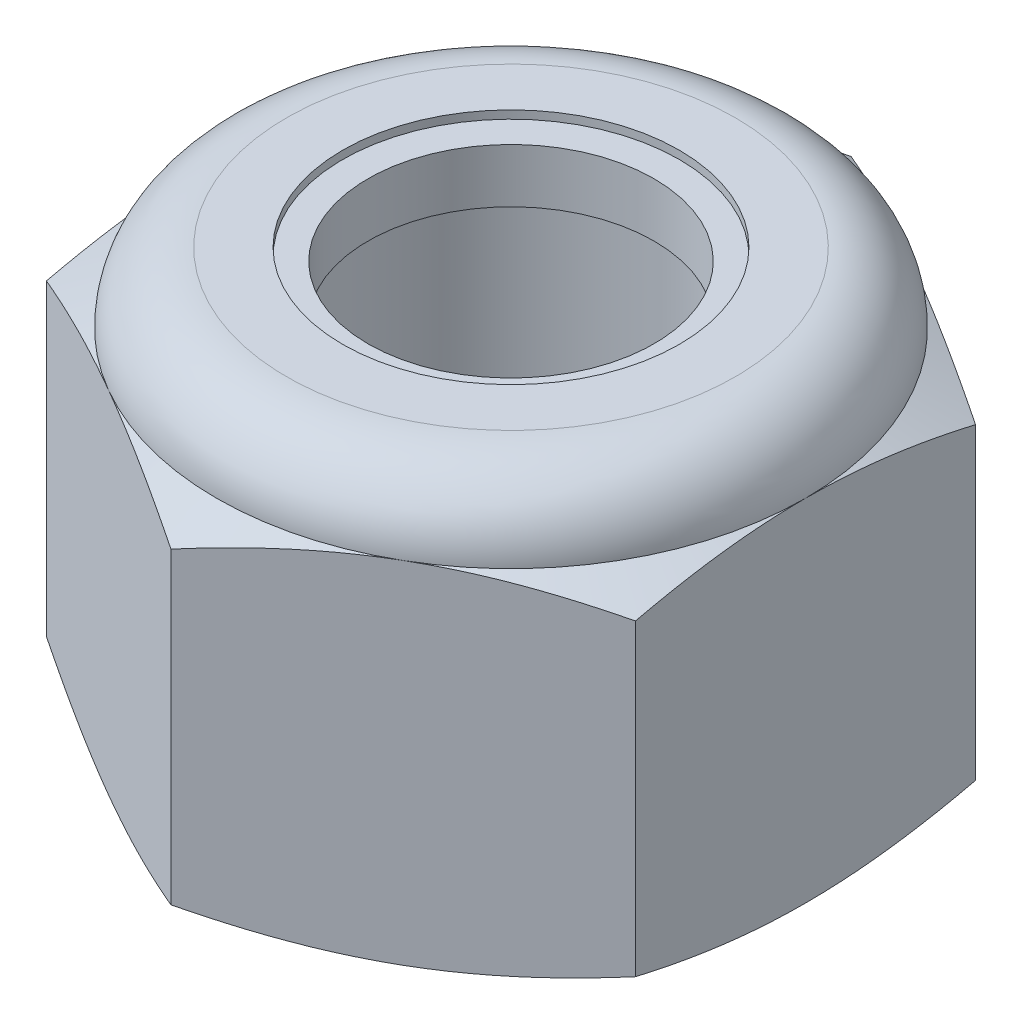
from build123d import *

# Parameters (mm, degrees)
SKETCH13_R     = 3.175
EXTRUDE1_DEPTH = 7.9375


with BuildPart() as part:
    # Sketch13 → Extrude1 (new body)
    with BuildSketch(Plane(origin=(0, 0, 0), x_dir=(1, 0, 0), z_dir=(0, 1, 0))):
        Polygon((0, 6.415804866), (-5.55625, 3.207902433), (-5.55625, -3.207902433), (0, -6.415804866), (5.55625, -3.207902433), (5.55625, 3.207902433), align=None)
        Circle(SKETCH13_R, mode=Mode.SUBTRACT)
    extrude(amount=EXTRUDE1_DEPTH)

    # Sketch5 → Cut-Revolve3 (revolve, cut)
    with BuildSketch(Plane(origin=(0, 0, 0), x_dir=(0, 0, -1), z_dir=(1, 0, 0))):
        with BuildLine():
            Line((0, 0), (5.55625, 0))
            Line((5.55625, 0), (6.415804866, 0.400817017))
            Line((6.415804866, 0.400817017), (6.415804866, 6.213766317))
            Line((6.415804866, 6.213766317), (5.55625, 6.614583333))
            ThreePointArc((5.55625, 6.614583333), (5.168776679, 7.550026679), (4.233333333, 7.9375))
            Line((4.233333333, 7.9375), (4.233333333, 9.2075))
            Line((4.233333333, 9.2075), (7.685804866, 9.2075))
            Line((7.685804866, 9.2075), (7.685804866, -1.27))
            Line((7.685804866, -1.27), (0, -1.27))
            Line((0, -1.27), (0, 0))
        make_face()
    revolve(axis=Axis((0, 0, 0), (0, 1, 0)), mode=Mode.SUBTRACT)

    # Sketch6 → Cut-Revolve4 (revolve, cut)
    with BuildSketch(Plane(origin=(0, 0, 0), x_dir=(0, 0, -1), z_dir=(1, 0, 0))):
        with BuildLine():
            Line((0, 6.614583333), (5.40385, 6.614583333))
            ThreePointArc((5.40385, 6.614583333), (5.061013606, 7.442263606), (4.233333333, 7.7851))
            Line((4.233333333, 7.7851), (2.116666667, 7.7851))
            Line((2.116666667, 7.7851), (2.116666667, 9.2075))
            Line((2.116666667, 9.2075), (0, 9.2075))
            Line((0, 9.2075), (0, 6.614583333))
        make_face()
    revolve(axis=Axis((0, 9.2075, 0), (0, -1, 0)), mode=Mode.SUBTRACT)

    # Sketch4 → Cut-Revolve2 (revolve, cut)
    with BuildSketch(Plane(origin=(0, 0, 0), x_dir=(0, 0, -1), z_dir=(1, 0, 0))):
        Polygon((0, 6.614583333), (3.4925, 6.614583333), (0, 4.986003837), align=None)
        Polygon((0, 1.628579496), (3.4925, 0), (0, 0), align=None)
    revolve(axis=Axis((0, 0, 0), (0, 1, 0)), mode=Mode.SUBTRACT)


with BuildPart() as body_2:
    # Sketch7 → Revolve2 (revolve)
    with BuildSketch(Plane(origin=(0, 0, 0), x_dir=(0, 0, -1), z_dir=(1, 0, 0))):
        with BuildLine():
            Line((2.69875, 6.690783333), (5.324993778, 6.690783333))
            ThreePointArc((5.324993778, 6.690783333), (4.979705237, 7.4148695), (4.233333333, 7.7089))
            Line((4.233333333, 7.7089), (2.69875, 7.7089))
            Line((2.69875, 7.7089), (2.69875, 6.690783333))
        make_face()
    revolve(axis=Axis((0, 6.690783333, 0), (0, 1, 0)))


solid = Compound([part.part, body_2.part])
